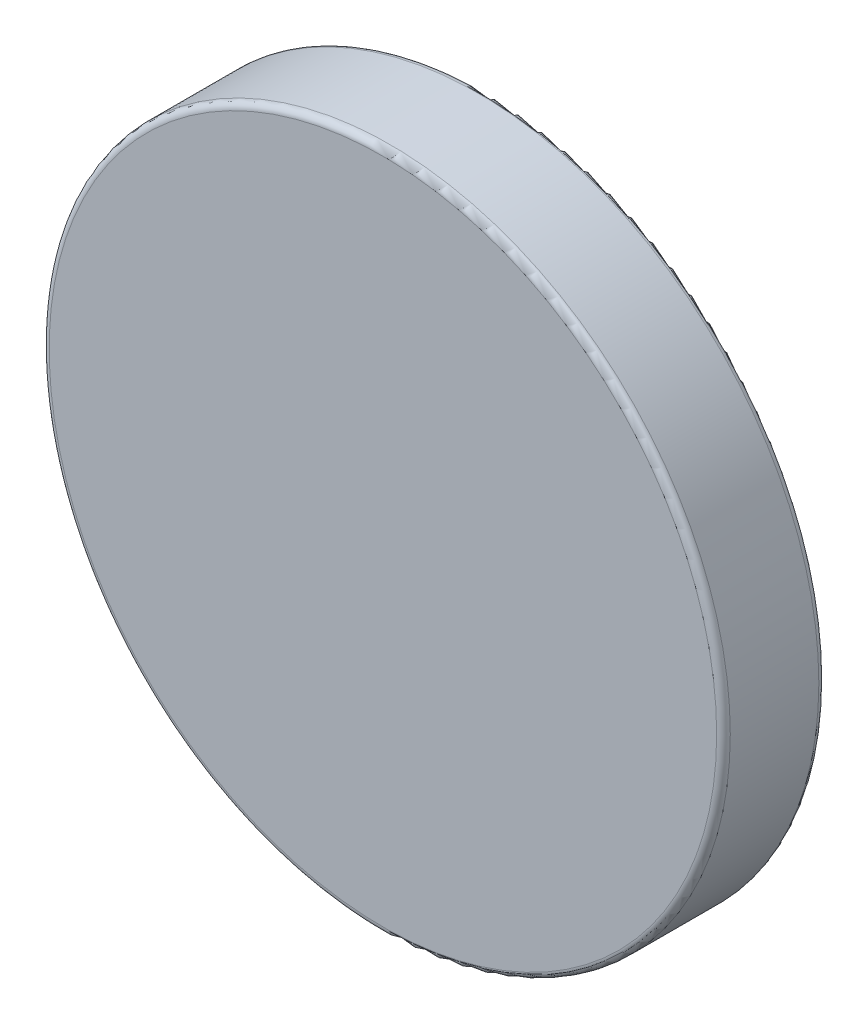
from build123d import *

# Parameters (mm, degrees)
SKETCH_1_R      = 10
EXTRUDE_1_DEPTH = 3
FILLET_1_R      = 0.2


with BuildPart() as part:
    # 草图1 → 凸台-拉伸1 (new body)
    with BuildSketch(Plane.XY):
        Circle(SKETCH_1_R)
    extrude(amount=EXTRUDE_1_DEPTH)

    # 圆角1
    fillet_1_edges = [part.edges().sort_by_distance(p)[0] for p in [
        (-10, 0, 0),
        (-10, 0, 3),
    ]]
    fillet(fillet_1_edges, radius=FILLET_1_R)


solid = part.part
